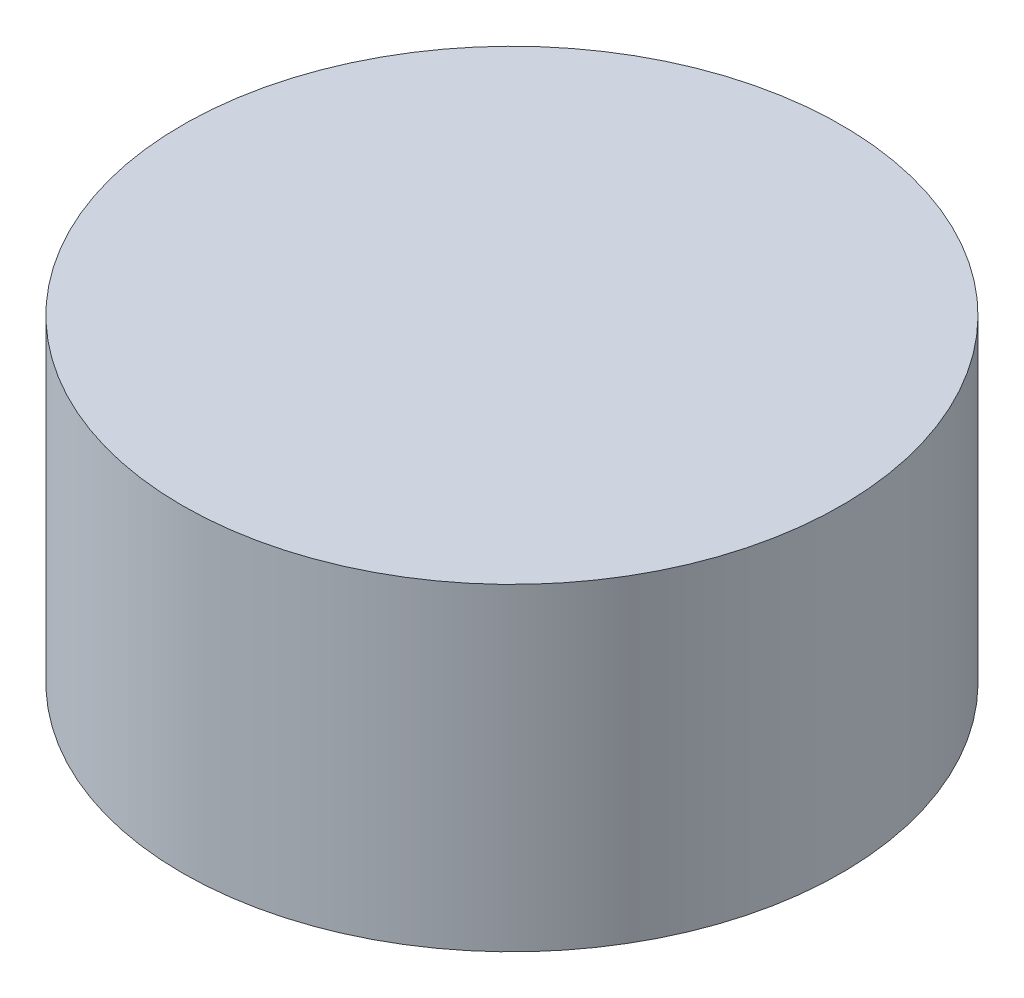
from build123d import *

# Parameters (mm, degrees)
SKETCH_1_R      = 29
EXTRUDE_1_DEPTH = 28


with BuildPart() as part:
    # 草图1 → 凸台-拉伸1 (new body)
    with BuildSketch(Plane(origin=(0, 0, 0), x_dir=(1, 0, 0), z_dir=(0, 1, 0))):
        Circle(SKETCH_1_R)
    extrude(amount=EXTRUDE_1_DEPTH)


solid = part.part
